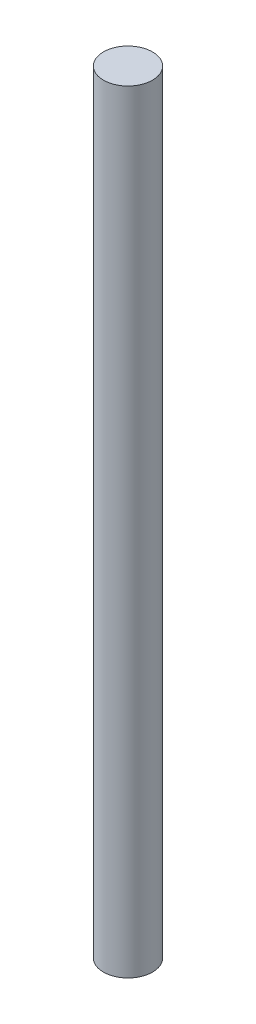
from build123d import *

# Parameters (mm, degrees)
SKETCH1_R           = 4
BOSS_EXTRUDE1_DEPTH = 126


with BuildPart() as part:
    # Sketch1 → Boss-Extrude1 (new body)
    with BuildSketch(Plane(origin=(0, 0, 0), x_dir=(1, 0, 0), z_dir=(0, 1, 0))):
        with Locations(Location((0, 0, 0), (0, 0, 270))):  # turned: the seam where the file's is
            Circle(SKETCH1_R)
    extrude(amount=BOSS_EXTRUDE1_DEPTH)


solid = part.part
